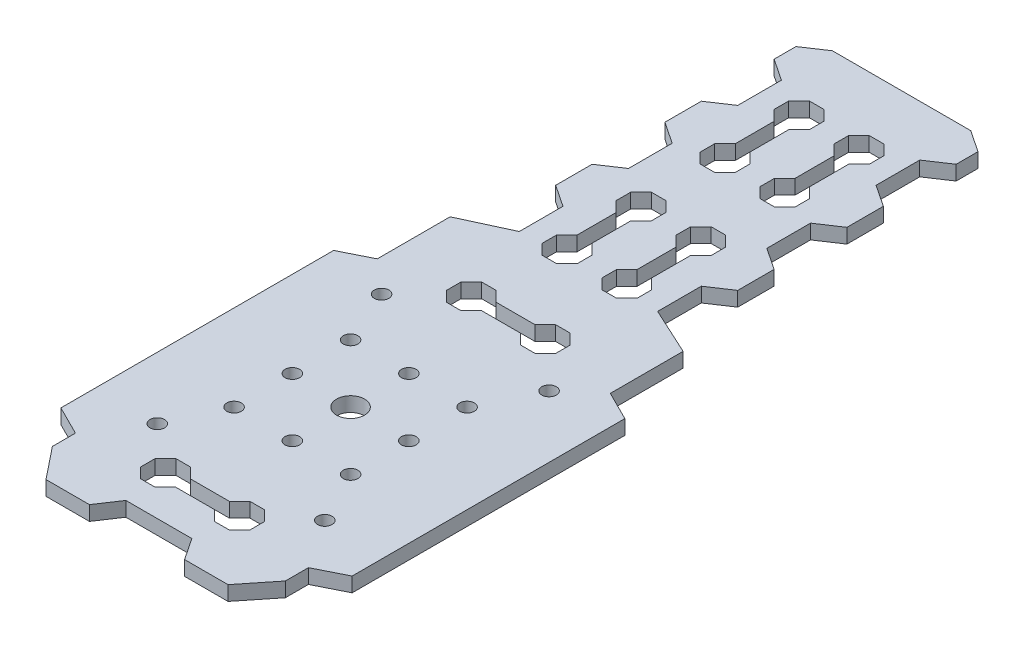
from build123d import *

# Parameters (mm, degrees)
BOSS_EXTRUDE1_DEPTH = 2
SKETCH2_R           = 1.92051595
SKETCH2_R_2         = 1
CUT_EXTRUDE1_DEPTH  = 10


with BuildPart() as part:
    # Sketch1 → Boss-Extrude1 (new body)
    with BuildSketch(Plane(origin=(0, 0, 0), x_dir=(1, 0, 0), z_dir=(0, 1, 0))):
        Polygon((0, 0), (4.532648702, 0), (6.532648702, -3), (12.5, -3), (16, 1.375958147), (16, 4.543860935), (20, 6.543860935), (20, 44), (16, 46), (16, 56), (9.5, 59), (9.5, 65), (12.5, 67), (12.5, 72), (9.5, 74), (9.5, 80), (12.5, 82), (12.5, 87), (9.5, 89), (9.5, 95), (12.5, 97), (12.5, 100), (9.5, 102), (0, 102), (0, 49), (2.671572875, 49), (4.085786438, 50.414213562), (6.085786438, 50.414213562), (7.5, 49), (7.5, 47), (6.085786438, 45.585786438), (4.085786438, 45.585786438), (2.671572875, 47), (0, 47), (0, 7), (2.671572875, 7), (4.085786438, 8.414213562), (6.085786438, 8.414213562), (7.5, 7), (7.5, 5), (6.085786438, 3.585786438), (4.085786438, 3.585786438), (2.671572875, 5), (0, 5), align=None)
        Polygon((3.111649133, 94.44670143), (5.111649133, 94.44670143), (6.525862696, 93.032487868), (6.525862696, 91.032487868), (5.111649133, 89.618274306), (5.111649133, 84.275128555), (6.525862696, 82.860914993), (6.525862696, 80.860914993), (5.111649133, 79.44670143), (3.111649133, 79.44670143), (1.697435571, 80.860914993), (1.697435571, 82.860914993), (3.111649133, 84.275128555), (3.111649133, 89.618274306), (1.697435571, 91.032487868), (1.697435571, 93.032487868), align=None, mode=Mode.SUBTRACT)
        Polygon((3.111649133, 72.74417146), (5.111649133, 72.74417146), (6.525862696, 71.329957898), (6.525862696, 69.329957898), (5.111649133, 67.915744336), (5.111649133, 62.572598585), (6.525862696, 61.158385023), (6.525862696, 59.158385023), (5.111649133, 57.74417146), (3.111649133, 57.74417146), (1.697435571, 59.158385023), (1.697435571, 61.158385023), (3.111649133, 62.572598585), (3.111649133, 67.915744336), (1.697435571, 69.329957898), (1.697435571, 71.329957898), align=None, mode=Mode.SUBTRACT)
    boss_extrude1 = extrude(amount=BOSS_EXTRUDE1_DEPTH)

    # Mirror1: Boss-Extrude1 across plane
    add(boss_extrude1.mirror(Plane(origin=(0, 0, 0), x_dir=(0, 0, 1), z_dir=(1, 0, 0))))

    # Sketch2 → Cut-Extrude1 (cut)
    with BuildSketch(Plane(origin=(0, 2, 0), x_dir=(1, 0, 0), z_dir=(0, 1, 0))):
        with Locations((-0.199550917, 26.529752726)):
            Circle(SKETCH2_R)
        with Locations((-8.199550917, 34.529752726)):
            Circle(SKETCH2_R_2)
        with Locations((-0.199550917, 34.529752726)):
            Circle(SKETCH2_R_2)
        with Locations((7.800449083, 34.529752726)):
            Circle(SKETCH2_R_2)
        with Locations((7.800449083, 26.529752726)):
            Circle(SKETCH2_R_2)
        with Locations((7.800449083, 18.529752726)):
            Circle(SKETCH2_R_2)
        with Locations((-0.199550917, 18.529752726)):
            Circle(SKETCH2_R_2)
        with Locations((-8.199550917, 18.529752726)):
            Circle(SKETCH2_R_2)
        with Locations((-8.199550917, 26.529752726)):
            Circle(SKETCH2_R_2)
        with Locations((-11.5, 42.089017941)):
            Circle(SKETCH2_R_2)
        with Locations((11.5, 42.089017941)):
            Circle(SKETCH2_R_2)
        with Locations((11.5, 11.285069421)):
            Circle(SKETCH2_R_2)
        with Locations((-11.5, 11.285069421)):
            Circle(SKETCH2_R_2)
    extrude(amount=-CUT_EXTRUDE1_DEPTH, mode=Mode.SUBTRACT)


solid = part.part
